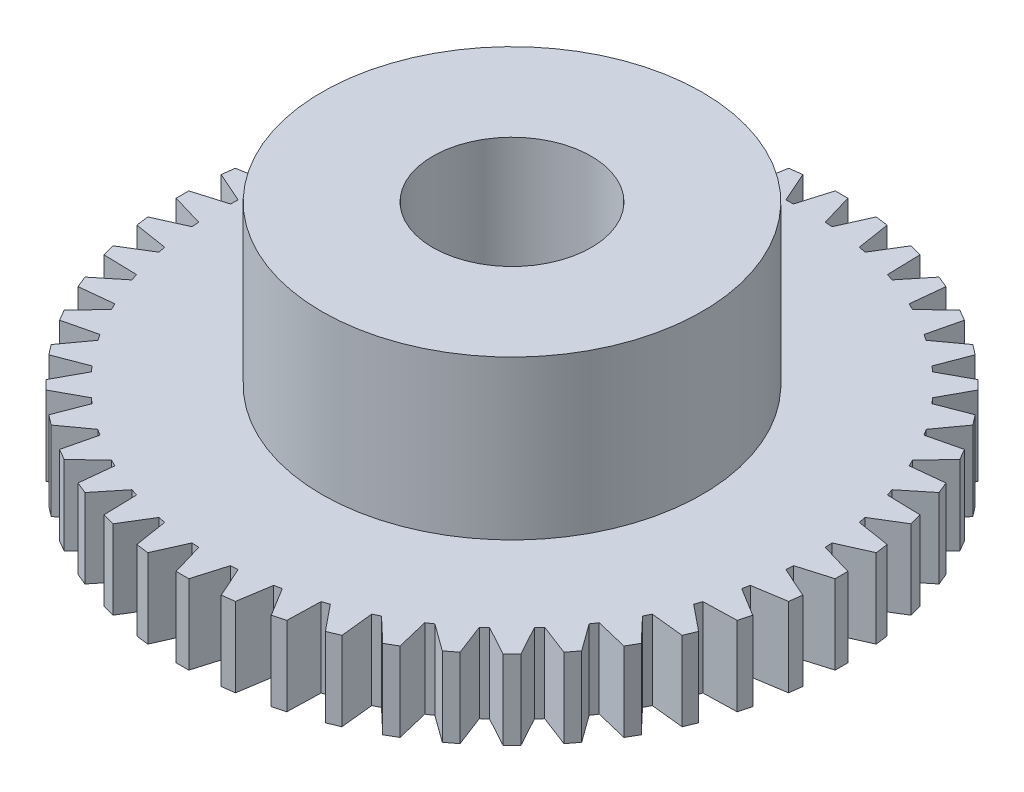
from build123d import *

# Parameters (mm, degrees)
SKETCH1_R           = 7.62
SKETCH1_R_2         = 3.175
BOSS_EXTRUDE1_DEPTH = 9.525
BOSS_EXTRUDE2_DEPTH = 3.175
BOSS_EXTRUDE3_DEPTH = 3.175
CIRPATTERN1_COUNT   = 48


with BuildPart() as part:
    # Sketch1 → Boss-Extrude1 (new body)
    with BuildSketch(Plane(origin=(0, 0, 0), x_dir=(1, 0, 0), z_dir=(0, 1, 0))):
        Circle(SKETCH1_R)
        Circle(SKETCH1_R_2, mode=Mode.SUBTRACT)
    extrude(amount=BOSS_EXTRUDE1_DEPTH)

    # Sketch2 → Boss-Extrude2 (add)
    with BuildSketch(Plane(origin=(0, 0, 0), x_dir=(1, 0, 0), z_dir=(0, 1, 0))):
        with BuildLine():
            Line((0.635, 11.92109974), (-0.635, 11.92109974))
            ThreePointArc((-0.635, 11.92109974), (-8.213866751, -8.663038555), (11.938, 0))
            ThreePointArc((11.938, 0), (8.663038555, 8.213866751), (0.635, 11.92109974))
        make_face()
    extrude(amount=BOSS_EXTRUDE2_DEPTH)

    # Sketch2_3 → Boss-Extrude3 (add)
    with BuildSketch(Plane(origin=(0, 0, 0), x_dir=(1, 0, 0), z_dir=(0, 1, 0))):
        Polygon((-0.635, 11.92109974), (0.635, 11.92109974), (0.254, 13.208), (-0.254, 13.208), align=None)
    boss_extrude3 = extrude(amount=BOSS_EXTRUDE3_DEPTH)

    # CirPattern1: Boss-Extrude3 ×48 about axis
    cirpattern1_axis = Axis((0, 9.525, 0), (0, -1, 0))
    for i in range(1, CIRPATTERN1_COUNT):
        add(boss_extrude3.rotate(cirpattern1_axis, i * 360 / CIRPATTERN1_COUNT))


solid = part.part
